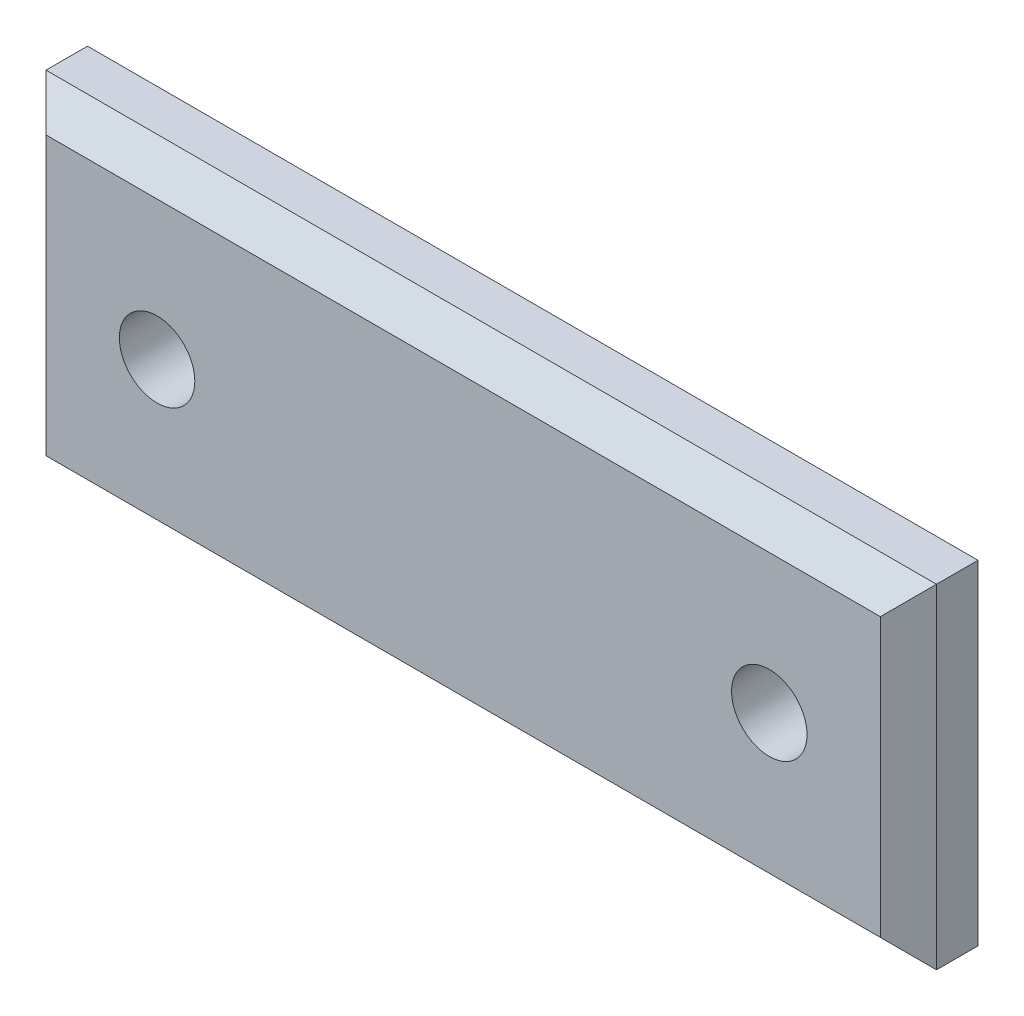
from build123d import *

# Parameters (mm, degrees)
SKETCH2_W             = 50.8
SKETCH2_H             = 19.05
BOSS_EXTRUDE1_DEPTH   = 3.96875
F_8_CLEARANCE_HOLE1_D = 4.3053
CHAMFER1_SIZE         = 1.6002


with BuildPart() as part:
    # Sketch2 → Boss-Extrude1 (new body)
    with BuildSketch(Plane.XY):
        Rectangle(SKETCH2_W, SKETCH2_H)
    extrude(amount=BOSS_EXTRUDE1_DEPTH)

    # #8 Clearance Hole1 (through all)
    with Locations(Plane.XY.offset(3.96875)):
        with Locations((-17.4625, 0), (17.4625, 0)):
            Hole(F_8_CLEARANCE_HOLE1_D / 2)

    # Chamfer1
    chamfer1_edges = [part.edges().sort_by_distance(p)[0] for p in [
        (-25.4, 0, 3.96875),
        (0, -9.525, 3.96875),
        (25.4, 0, 3.96875),
        (0, 9.525, 3.96875),
    ]]
    chamfer(chamfer1_edges, length=CHAMFER1_SIZE)


solid = part.part
